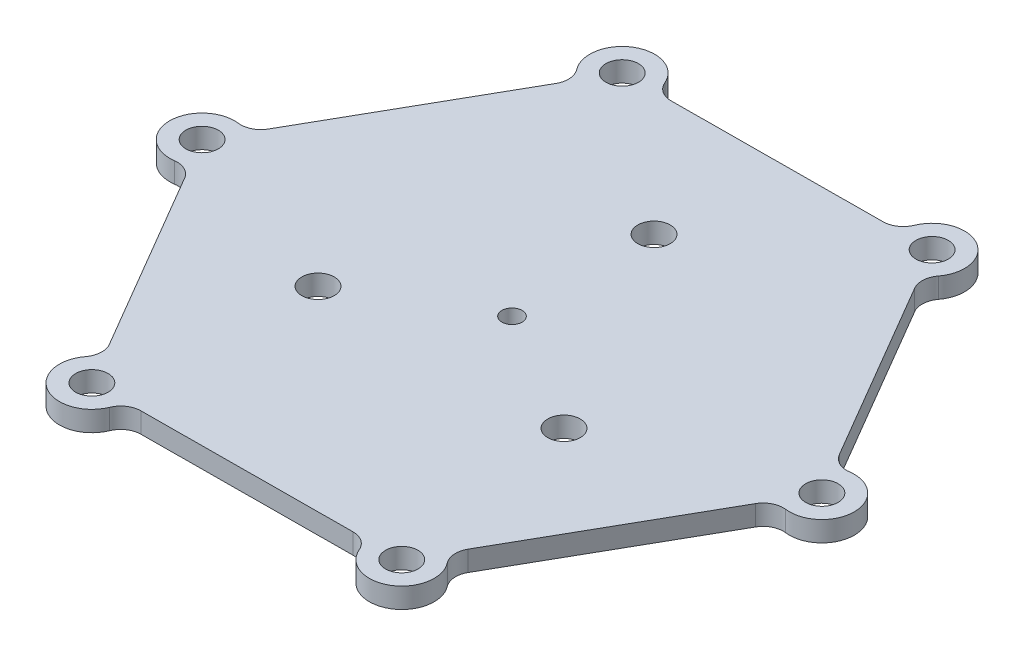
from build123d import *

# Parameters (mm, degrees)
ESQUISSE1_R        = 8
ESQUISSE1_R_2      = 5
BOSS_EXTRU_2_DEPTH = 10


with BuildPart() as part:
    # Esquisse1 → Boss.-Extru.2 (new body)
    with BuildSketch(Plane(origin=(0, 0, 0), x_dir=(1, 0, 0), z_dir=(0, 1, 0))):
        with BuildLine():
            Line((88.589203043, -110.181902046), (139.966204056, -19.938910608))
            ThreePointArc((139.966204056, -19.938910608), (144.170152865, -15.949329734), (149.881071002, -14.961729023))
            ThreePointArc((149.881071002, -14.961729023), (167.84005434, 1.014572883), (149.689240839, 16.772595422))
            ThreePointArc((149.689240839, 16.772595422), (143.966800629, 17.691082861), (139.71492773, 21.629549313))
            Line((139.71492773, 21.629549313), (87.250705139, 111.24483308))
            ThreePointArc((87.250705139, 111.24483308), (85.897601156, 116.880349981), (87.897772919, 122.319950523))
            ThreePointArc((87.897772919, 122.319950523), (83.04138128, 145.861037272), (60.319126696, 138.02098295))
            ThreePointArc((60.319126696, 138.02098295), (56.662473136, 133.524448077), (51.125724688, 131.811451359))
            Line((51.125724688, 131.811451359), (-52.715498918, 131.183743688))
            ThreePointArc((-52.715498918, 131.183743688), (-58.272551709, 132.829679716), (-61.983298082, 137.281679546))
            ThreePointArc((-61.983298082, 137.281679546), (-84.79867306, 144.846464389), (-89.370114142, 121.248387528))
            ThreePointArc((-89.370114142, 121.248387528), (-87.304327493, 115.833365215), (-88.589203043, 110.181902046))
            Line((-88.589203043, 110.181902046), (-139.966204056, 19.938910608))
            ThreePointArc((-139.966204056, 19.938910608), (-144.170152865, 15.949329734), (-149.881071002, 14.961729023))
            ThreePointArc((-149.881071002, 14.961729023), (-167.84005434, -1.014572883), (-149.689240839, -16.772595422))
            ThreePointArc((-149.689240839, -16.772595422), (-143.966800629, -17.691082861), (-139.71492773, -21.629549313))
            Line((-139.71492773, -21.629549313), (-87.250705139, -111.24483308))
            ThreePointArc((-87.250705139, -111.24483308), (-85.897601156, -116.880349981), (-87.897772919, -122.319950523))
            ThreePointArc((-87.897772919, -122.319950523), (-83.04138128, -145.861037272), (-60.319126696, -138.02098295))
            ThreePointArc((-60.319126696, -138.02098295), (-56.662473136, -133.524448077), (-51.125724688, -131.811451359))
            Line((-51.125724688, -131.811451359), (52.715498918, -131.183743688))
            ThreePointArc((52.715498918, -131.183743688), (58.272551709, -132.829679716), (61.983298082, -137.281679546))
            ThreePointArc((61.983298082, -137.281679546), (84.79867306, -144.846464389), (89.370114142, -121.248387528))
            ThreePointArc((89.370114142, -121.248387528), (87.304327493, -115.833365215), (88.589203043, -110.181902046))
        make_face()
        with Locations(Location((-151.840346656, -0.91785658, 0), (0, 0, 270))):  # turned: the seam where the file's is
            Circle(ESQUISSE1_R, mode=Mode.SUBTRACT)
        with Locations(Location((-76.715060443, 131.038669234, 0), (0, 0, 270))):  # turned: the seam where the file's is
            Circle(ESQUISSE1_R, mode=Mode.SUBTRACT)
        with Locations(Location((75.125286213, 131.956525813, 0), (0, 0, 270))):  # turned: the seam where the file's is
            Circle(ESQUISSE1_R, mode=Mode.SUBTRACT)
        with Locations(Location((151.840346656, 0.91785658, 0), (0, 0, 270))):  # turned: the seam where the file's is
            Circle(ESQUISSE1_R, mode=Mode.SUBTRACT)
        with Locations(Location((76.715060443, -131.038669234, 0), (0, 0, 270))):  # turned: the seam where the file's is
            Circle(ESQUISSE1_R, mode=Mode.SUBTRACT)
        with Locations(Location((-75.125286213, -131.956525813, 0), (0, 0, 270))):  # turned: the seam where the file's is
            Circle(ESQUISSE1_R, mode=Mode.SUBTRACT)
        with Locations(Location((0, 70, 0), (0, 0, 270))):  # turned: the seam where the file's is
            Circle(ESQUISSE1_R, mode=Mode.SUBTRACT)
        with Locations(Location((60.621778265, -35, 0), (0, 0, 270))):  # turned: the seam where the file's is
            Circle(ESQUISSE1_R, mode=Mode.SUBTRACT)
        with Locations(Location((-60.621778265, -35, 0), (0, 0, 270))):  # turned: the seam where the file's is
            Circle(ESQUISSE1_R, mode=Mode.SUBTRACT)
        with Locations(Location((0, 0, 0), (0, 0, 270))):  # turned: the seam where the file's is
            Circle(ESQUISSE1_R_2, mode=Mode.SUBTRACT)
    extrude(amount=-BOSS_EXTRU_2_DEPTH)


solid = part.part
